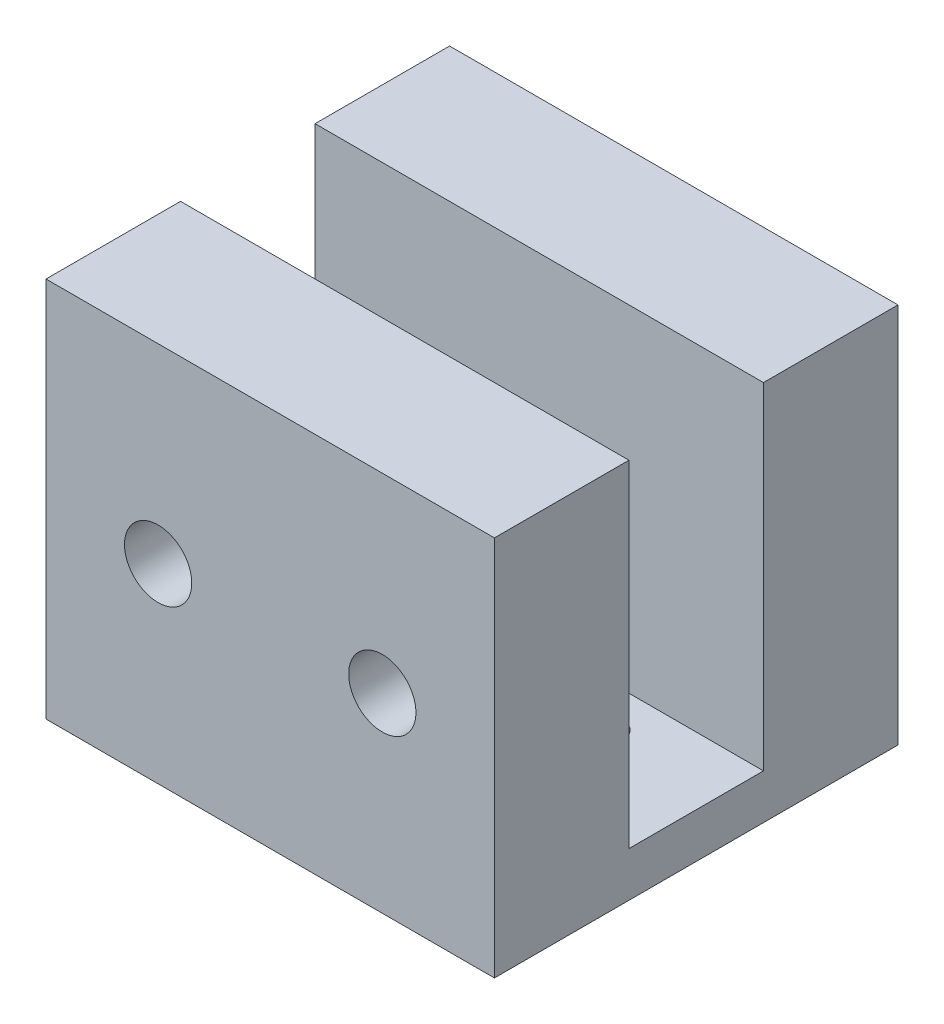
from build123d import *

# Parameters (mm, degrees)
ESQUISSE1_W             = 20
ESQUISSE1_H             = 6
BOSS_EXTRU_1_DEPTH      = 2
ESQUISSE1_4_W           = 20
ESQUISSE1_4_H           = 6
BOSS_EXTRU_2_DEPTH      = 17
ESQUISSE1_5_W           = 20
ESQUISSE1_5_H           = 6
BOSS_EXTRU_3_DEPTH      = 17
ENL_V_MAT_EXTRU_1_REACH = 28.702
ESQUISSE2_R             = 1.5
ENL_V_MAT_EXTRU_2_REACH = 23.679
ESQUISSE3_R             = 0.85


with BuildPart() as part:
    # Esquisse1 → Boss.-Extru.1 (new body)
    with BuildSketch(Plane(origin=(0, 0, 0), x_dir=(1, 0, 0), z_dir=(0, 1, 0))):
        Rectangle(ESQUISSE1_W, ESQUISSE1_H)
    extrude(amount=BOSS_EXTRU_1_DEPTH)

    # Esquisse1_4 → Boss.-Extru.2 (add)
    with BuildSketch(Plane(origin=(0, 0, 0), x_dir=(1, 0, 0), z_dir=(0, 1, 0))):
        with Locations((0, -6)):
            Rectangle(ESQUISSE1_4_W, ESQUISSE1_4_H)
    extrude(amount=BOSS_EXTRU_2_DEPTH)

    # Esquisse1_5 → Boss.-Extru.3 (add)
    with BuildSketch(Plane(origin=(0, 0, 0), x_dir=(1, 0, 0), z_dir=(0, 1, 0))):
        with Locations((0, 6)):
            Rectangle(ESQUISSE1_5_W, ESQUISSE1_5_H)
    extrude(amount=BOSS_EXTRU_3_DEPTH)

    # Esquisse2 → Enlèv. mat.-Extru.1 (cut, up to next)
    with BuildSketch(Plane.XY.offset(9), mode=Mode.PRIVATE) as enl_v_mat_extru_1_sk1:
        with Locations((-5, 8.5)):
            Circle(ESQUISSE2_R)
    enl_v_mat_extru_1_tool1 = extrude(enl_v_mat_extru_1_sk1.sketch, amount=-ENL_V_MAT_EXTRU_1_REACH, mode=Mode.PRIVATE) & part.part
    # Esquisse2 → Enlèv. mat.-Extru.1 (cut, up to next)
    with BuildSketch(Plane.XY.offset(9), mode=Mode.PRIVATE) as enl_v_mat_extru_1_sk2:
        with Locations((5, 8.5)):
            Circle(ESQUISSE2_R)
    enl_v_mat_extru_1_tool2 = extrude(enl_v_mat_extru_1_sk2.sketch, amount=-ENL_V_MAT_EXTRU_1_REACH, mode=Mode.PRIVATE) & part.part
    add(enl_v_mat_extru_1_tool1.solids().sort_by_distance((-5, 8.5, 9))[0], mode=Mode.SUBTRACT)
    add(enl_v_mat_extru_1_tool2.solids().sort_by_distance((5, 8.5, 9))[0], mode=Mode.SUBTRACT)

    # Esquisse3 → Enlèv. mat.-Extru.2 (cut, up to next)
    with BuildSketch(Plane.XZ, mode=Mode.PRIVATE) as enl_v_mat_extru_2_sk1:
        with Locations((-4.85, -1)):
            Circle(ESQUISSE3_R)
    enl_v_mat_extru_2_tool1 = extrude(enl_v_mat_extru_2_sk1.sketch, amount=-ENL_V_MAT_EXTRU_2_REACH, mode=Mode.PRIVATE) & part.part
    # Esquisse3 → Enlèv. mat.-Extru.2 (cut, up to next)
    with BuildSketch(Plane.XZ, mode=Mode.PRIVATE) as enl_v_mat_extru_2_sk2:
        with Locations((4.85, -1)):
            Circle(ESQUISSE3_R)
    enl_v_mat_extru_2_tool2 = extrude(enl_v_mat_extru_2_sk2.sketch, amount=-ENL_V_MAT_EXTRU_2_REACH, mode=Mode.PRIVATE) & part.part
    add(enl_v_mat_extru_2_tool1.solids().sort_by_distance((-4.85, 0, -1))[0], mode=Mode.SUBTRACT)
    add(enl_v_mat_extru_2_tool2.solids().sort_by_distance((4.85, 0, -1))[0], mode=Mode.SUBTRACT)


solid = part.part
